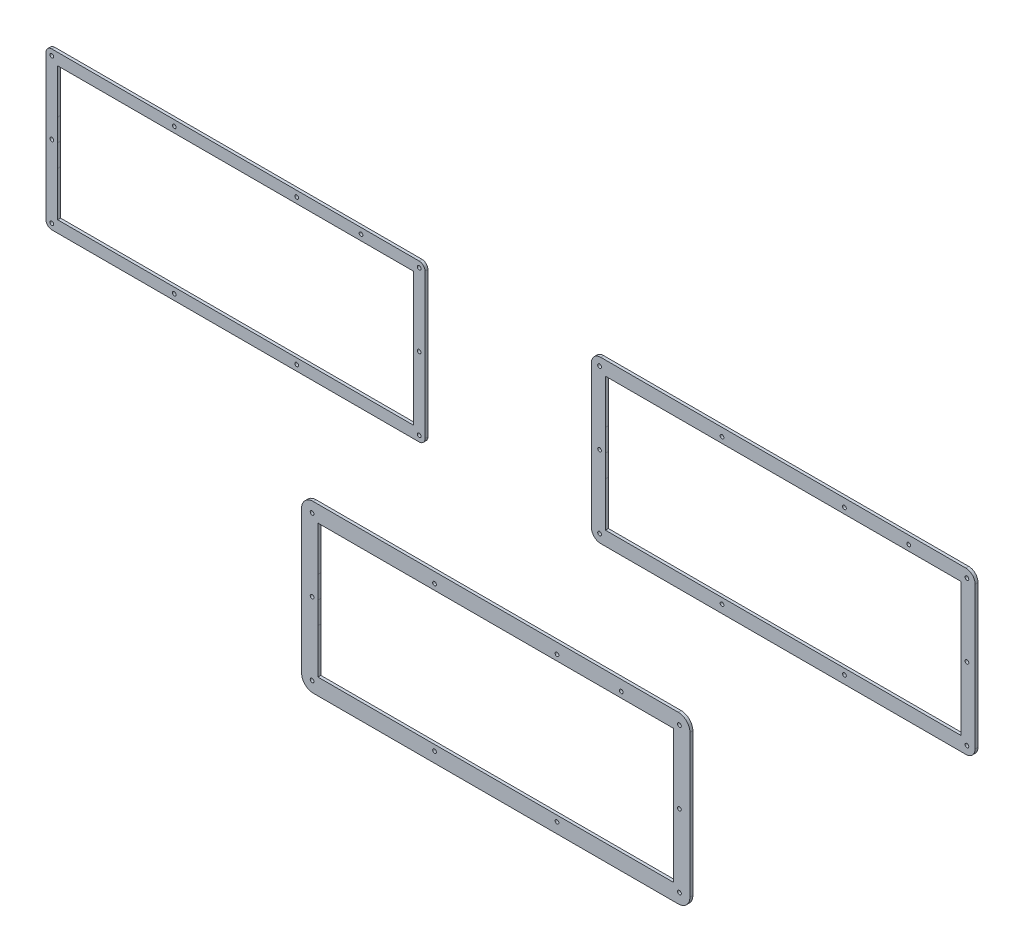
from build123d import *

# Parameters (mm, degrees)
SKETCH_3_R        = 1.6
SKETCH_3_R_2      = 1.5998
SKETCH_3_R_3      = 1.59992
EXTRUDE_2_DEPTH   = 2.5
EXTRUDE_2_2_DEPTH = 2.5
EXTRUDE_2_3_DEPTH = 2.5


with BuildPart() as part:
    # 草图3 → 凸台-拉伸2 (new body)
    with BuildSketch(Plane.XY):
        with BuildLine():
            Line((452.073308623, 140.342337287), (764.875224023, 140.342337287))
            ThreePointArc((764.875224023, 140.342337287), (771.946291835, 137.413405099), (774.875224023, 130.342337287))
            Line((774.875224023, 130.342337287), (774.875224023, 8.040251287))
            ThreePointArc((774.875224023, 8.040251287), (771.946291835, 0.969183475), (764.875224023, -1.959748713))
            Line((764.875224023, -1.959748713), (452.073308623, -1.959748713))
            ThreePointArc((452.073308623, -1.959748713), (445.002240811, 0.969183475), (442.073308623, 8.040251287))
            Line((442.073308623, 8.040251287), (442.073308623, 130.342337287))
            ThreePointArc((442.073308623, 130.342337287), (445.002240811, 137.413405099), (452.073308623, 140.342337287))
        make_face()
        with Locations((660.940224023, 131.342337287)):
            Circle(SKETCH_3_R, mode=Mode.SUBTRACT)
        with Locations((716.008224023, 131.342337287)):
            Circle(SKETCH_3_R, mode=Mode.SUBTRACT)
        with Locations((765.875224023, 131.342337287)):
            Circle(SKETCH_3_R, mode=Mode.SUBTRACT)
        with Locations((765.875224023, 69.191237287)):
            Circle(SKETCH_3_R_2, mode=Mode.SUBTRACT)
        with Locations((765.875224023, 7.040237287)):
            Circle(SKETCH_3_R_3, mode=Mode.SUBTRACT)
        with Locations((660.940224023, 7.040237287)):
            Circle(SKETCH_3_R_3, mode=Mode.SUBTRACT)
        with Locations((556.007224023, 7.040237287)):
            Circle(SKETCH_3_R_3, mode=Mode.SUBTRACT)
        with Locations((451.073294023, 7.040237287)):
            Circle(SKETCH_3_R_3, mode=Mode.SUBTRACT)
        with Locations((451.073294023, 69.191237287)):
            Circle(SKETCH_3_R_2, mode=Mode.SUBTRACT)
        with Locations((451.073294023, 131.342337287)):
            Circle(SKETCH_3_R, mode=Mode.SUBTRACT)
        with Locations((556.007224023, 131.342337287)):
            Circle(SKETCH_3_R, mode=Mode.SUBTRACT)
        Polygon((456.071444023, 126.344337287), (456.071444023, 88.241237287), (456.072814023, 88.241237287), (456.072814023, 69.192637287), (456.071444023, 69.192637287), (456.071444023, 50.141237287), (456.072814023, 50.141237287), (456.072814023, 12.041147287), (760.874224023, 12.041147287), (760.874224023, 126.344337287), align=None, mode=Mode.SUBTRACT)
    extrude(amount=EXTRUDE_2_DEPTH)


with BuildPart() as body_2:
    # 草图3 → Extrude 2 2 (new body)
    with BuildSketch(Plane.XY):
        with BuildLine():
            Line((228.031386011, 364.206373848), (542.833301411, 364.206373848))
            ThreePointArc((542.833301411, 364.206373848), (546.368835317, 362.741907753), (547.833301411, 359.206373848))
            Line((547.833301411, 359.206373848), (547.833301411, 234.904287848))
            ThreePointArc((547.833301411, 234.904287848), (546.368835317, 231.368753942), (542.833301411, 229.904287848))
            Line((542.833301411, 229.904287848), (228.031386011, 229.904287848))
            ThreePointArc((228.031386011, 229.904287848), (224.495852105, 231.368753942), (223.031386011, 234.904287848))
            Line((223.031386011, 234.904287848), (223.031386011, 359.206373848))
            ThreePointArc((223.031386011, 359.206373848), (224.495852105, 362.741907753), (228.031386011, 364.206373848))
        make_face()
        with Locations((437.898301411, 359.206373848)):
            Circle(SKETCH_3_R, mode=Mode.SUBTRACT)
        with Locations((492.966301411, 359.206373848)):
            Circle(SKETCH_3_R, mode=Mode.SUBTRACT)
        with Locations((542.833301411, 359.206373848)):
            Circle(SKETCH_3_R, mode=Mode.SUBTRACT)
        with Locations((542.833301411, 297.055273848)):
            Circle(SKETCH_3_R_2, mode=Mode.SUBTRACT)
        with Locations((542.833301411, 234.904273848)):
            Circle(SKETCH_3_R_3, mode=Mode.SUBTRACT)
        with Locations((437.898301411, 234.904273848)):
            Circle(SKETCH_3_R_3, mode=Mode.SUBTRACT)
        with Locations((332.965301411, 234.904273848)):
            Circle(SKETCH_3_R_3, mode=Mode.SUBTRACT)
        with Locations((228.031371411, 234.904273848)):
            Circle(SKETCH_3_R_3, mode=Mode.SUBTRACT)
        with Locations((228.031371411, 297.055273848)):
            Circle(SKETCH_3_R_2, mode=Mode.SUBTRACT)
        with Locations((228.031371411, 359.206373848)):
            Circle(SKETCH_3_R, mode=Mode.SUBTRACT)
        with Locations((332.965301411, 359.206373848)):
            Circle(SKETCH_3_R, mode=Mode.SUBTRACT)
        Polygon((233.029521411, 354.208373848), (233.029521411, 316.105273848), (233.030891411, 316.105273848), (233.030891411, 297.056673848), (233.029521411, 297.056673848), (233.029521411, 278.005273848), (233.030891411, 278.005273848), (233.030891411, 239.905183848), (537.832301411, 239.905183848), (537.832301411, 354.208373848), align=None, mode=Mode.SUBTRACT)
    extrude(amount=EXTRUDE_2_2_DEPTH)


with BuildPart() as body_3:
    # 草图3 → Extrude 2 3 (new body)
    with BuildSketch(Plane.XY):
        with BuildLine():
            Line((698.467197982, 370.563797332), (1011.269113382, 370.563797332))
            ThreePointArc((1011.269113382, 370.563797332), (1016.925967632, 368.220651581), (1019.269113382, 362.563797332))
            Line((1019.269113382, 362.563797332), (1019.269113382, 240.261711332))
            ThreePointArc((1019.269113382, 240.261711332), (1016.925967632, 234.604857082), (1011.269113382, 232.261711332))
            Line((1011.269113382, 232.261711332), (698.467197982, 232.261711332))
            ThreePointArc((698.467197982, 232.261711332), (692.810343733, 234.604857082), (690.467197982, 240.261711332))
            Line((690.467197982, 240.261711332), (690.467197982, 362.563797332))
            ThreePointArc((690.467197982, 362.563797332), (692.810343733, 368.220651581), (698.467197982, 370.563797332))
        make_face()
        with Locations((907.334113382, 363.563797332)):
            Circle(SKETCH_3_R, mode=Mode.SUBTRACT)
        with Locations((962.402113382, 363.563797332)):
            Circle(SKETCH_3_R, mode=Mode.SUBTRACT)
        with Locations((1012.269113382, 363.563797332)):
            Circle(SKETCH_3_R, mode=Mode.SUBTRACT)
        with Locations((1012.269113382, 301.412697332)):
            Circle(SKETCH_3_R_2, mode=Mode.SUBTRACT)
        with Locations((1012.269113382, 239.261697332)):
            Circle(SKETCH_3_R_3, mode=Mode.SUBTRACT)
        with Locations((907.334113382, 239.261697332)):
            Circle(SKETCH_3_R_3, mode=Mode.SUBTRACT)
        with Locations((802.401113382, 239.261697332)):
            Circle(SKETCH_3_R_3, mode=Mode.SUBTRACT)
        with Locations((697.467183382, 239.261697332)):
            Circle(SKETCH_3_R_3, mode=Mode.SUBTRACT)
        with Locations((697.467183382, 301.412697332)):
            Circle(SKETCH_3_R_2, mode=Mode.SUBTRACT)
        with Locations((697.467183382, 363.563797332)):
            Circle(SKETCH_3_R, mode=Mode.SUBTRACT)
        with Locations((802.401113382, 363.563797332)):
            Circle(SKETCH_3_R, mode=Mode.SUBTRACT)
        Polygon((702.465333382, 358.565797332), (702.465333382, 320.462697332), (702.466703382, 320.462697332), (702.466703382, 301.414097332), (702.465333382, 301.414097332), (702.465333382, 282.362697332), (702.466703382, 282.362697332), (702.466703382, 244.262607332), (1007.268113382, 244.262607332), (1007.268113382, 358.565797332), align=None, mode=Mode.SUBTRACT)
    extrude(amount=EXTRUDE_2_3_DEPTH)


solid = Compound([part.part, body_2.part, body_3.part])
